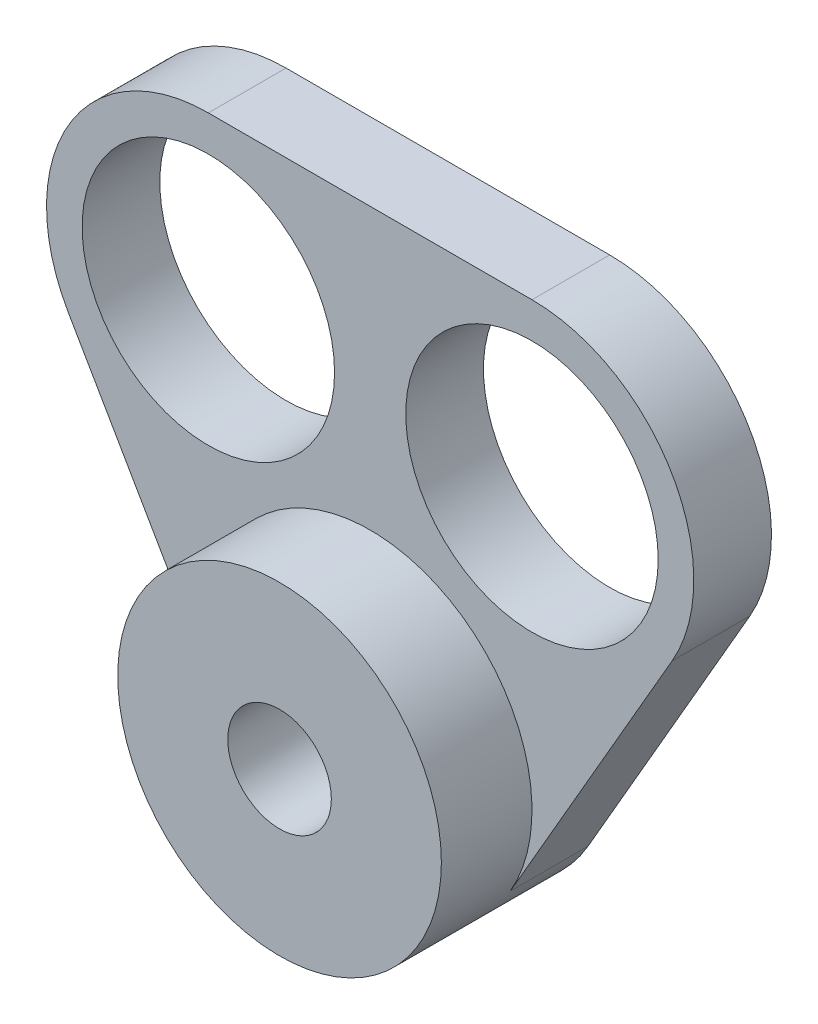
from build123d import *

# Parameters (mm, degrees)
CROQUIS1_R              = 9.75
SALIENTE_EXTRUIR1_DEPTH = 6
CROQUIS2_R              = 12.5
CROQUIS2_R_2            = 4
SALIENTE_EXTRUIR3_DEPTH = 7


with BuildPart() as part:
    # Croquis1 → Saliente-Extruir1 (new body)
    with BuildSketch(Plane.XY):
        with BuildLine():
            Line((-23.325317547, 15.400635095), (-10.825317547, -6.25))
            ThreePointArc((-10.825317547, -6.25), (0, -12.5), (10.825317547, -6.25))
            Line((10.825317547, -6.25), (23.325317547, 15.400635095))
            ThreePointArc((23.325317547, 15.400635095), (23.325317547, 27.900635095), (12.5, 34.150635095))
            Line((12.5, 34.150635095), (-12.5, 34.150635095))
            ThreePointArc((-12.5, 34.150635095), (-23.325317547, 27.900635095), (-23.325317547, 15.400635095))
        make_face()
        Circle(CROQUIS1_R, mode=Mode.SUBTRACT)
        with Locations((12.5, 21.650635095)):
            Circle(CROQUIS1_R, mode=Mode.SUBTRACT)
        with Locations((-12.5, 21.650635095)):
            Circle(CROQUIS1_R, mode=Mode.SUBTRACT)
    extrude(amount=SALIENTE_EXTRUIR1_DEPTH)

    # Croquis2 → Saliente-Extruir3 (add)
    with BuildSketch(Plane.XY.offset(6)):
        Circle(CROQUIS2_R)
        Circle(CROQUIS2_R_2, mode=Mode.SUBTRACT)
    extrude(amount=SALIENTE_EXTRUIR3_DEPTH)


solid = part.part
